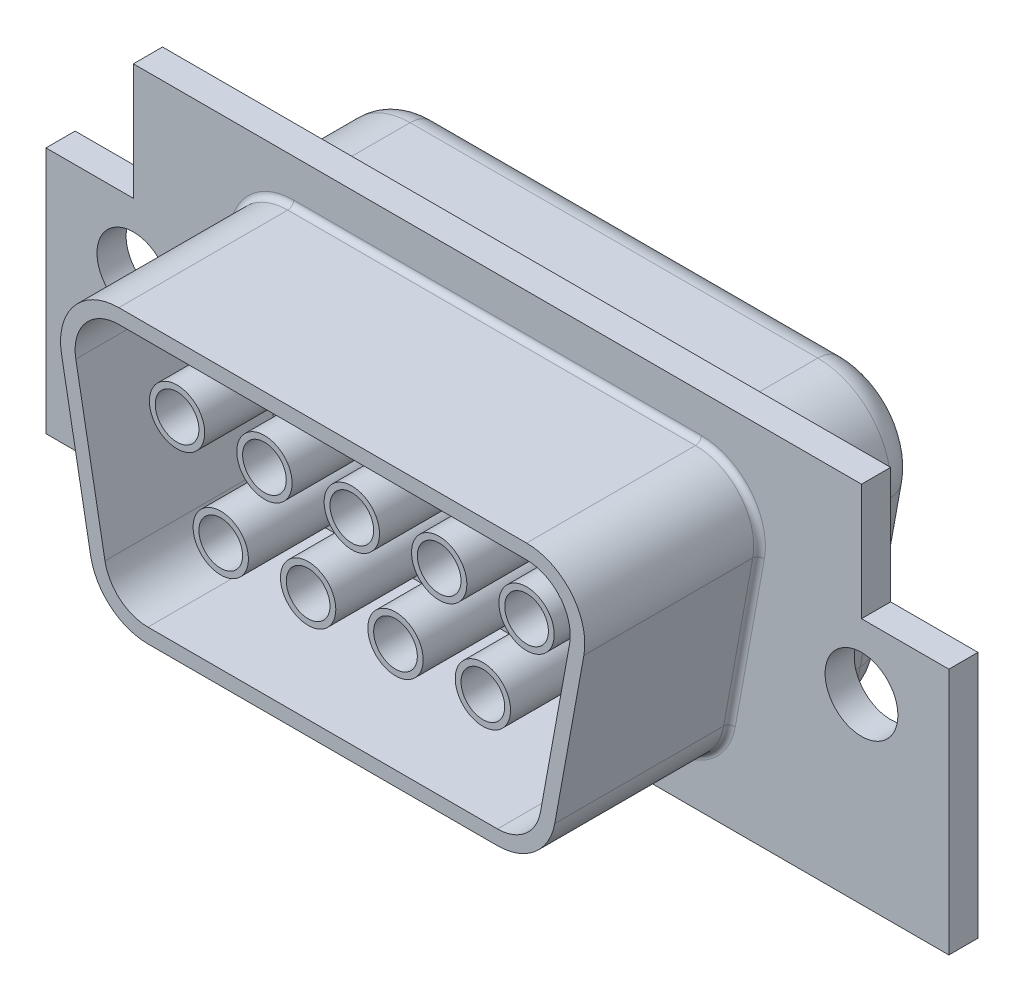
from build123d import *

# Parameters (mm, degrees)
SKETCH1_W                 = 31
SKETCH1_H                 = 12.5
EXTRUDE1_DEPTH            = 1
EXTRUDE2_DEPTH            = 6
FILLET1_R                 = 0.2
M3X0_5_TAPPED_HOLE1_D     = 2.5
M3X0_5_TAPPED_HOLE1_DEPTH = 17.5
M3X0_5_TAPPED_HOLE1_TIP   = 0.751075774
EXTRUDE3_DEPTH            = 4
FILLET2_R                 = 1
EXTRUDE4_DEPTH            = 0.5
SKETCH8_R                 = 0.95
SKETCH8_R_2               = 0.75
EXTRUDE_THIN2_DEPTH       = 5
SKETCH10_W                = 6.420651052
SKETCH10_H                = 6.175896966
SKETCH10_W_2              = 7.637064352
SKETCH10_H_2              = 8.744155905
CUT_EXTRUDE1_DEPTH        = 5


with BuildPart() as part:
    # Sketch1 → Extrude1 (new body)
    with BuildSketch(Plane.XY):
        Rectangle(SKETCH1_W, SKETCH1_H)
    extrude(amount=EXTRUDE1_DEPTH)

    # Sketch2 → Extrude2 (add)
    with BuildSketch(Plane.XY.offset(1)):
        with BuildLine():
            Line((-7, 4.75), (7, 4.75))
            ThreePointArc((7, 4.75), (8.53550346, 4.031494878), (8.96773982, 2.392229124))
            Line((8.96773982, 2.392229124), (7.96773982, -3.107770876))
            ThreePointArc((7.96773982, -3.107770876), (7.281494878, -4.28550346), (6, -4.75))
            Line((6, -4.75), (-6, -4.75))
            ThreePointArc((-6, -4.75), (-7.281494878, -4.28550346), (-7.96773982, -3.107770876))
            Line((-7.96773982, -3.107770876), (-8.96773982, 2.392229124))
            ThreePointArc((-8.96773982, 2.392229124), (-8.53550346, 4.031494878), (-7, 4.75))
        make_face()
        with BuildLine():
            Line((-6, -4.25), (6, -4.25))
            ThreePointArc((6, -4.25), (6.961121159, -3.901627595), (7.475804865, -3.018328157))
            Line((7.475804865, -3.018328157), (8.475804865, 2.481671843))
            ThreePointArc((8.475804865, 2.481671843), (8.151627595, 3.711121159), (7, 4.25))
            Line((7, 4.25), (-7, 4.25))
            ThreePointArc((-7, 4.25), (-8.151627595, 3.711121159), (-8.475804865, 2.481671843))
            Line((-8.475804865, 2.481671843), (-7.475804865, -3.018328157))
            ThreePointArc((-7.475804865, -3.018328157), (-6.961121159, -3.901627595), (-6, -4.25))
        make_face(mode=Mode.SUBTRACT)
    extrude(amount=EXTRUDE2_DEPTH)

    # Fillet1
    fillet1_edges = [part.edges().sort_by_distance(p)[0] for p in [
        (-7.281494878, -4.28550346, 1),
        (0, -4.75, 1),
        (7.281494878, -4.28550346, 1),
        (8.46773982, -0.357770876, 1),
        (8.53550346, 4.031494878, 1),
        (0, 4.75, 1),
        (-8.53550346, 4.031494878, 1),
        (-8.46773982, -0.357770876, 1),
    ]]
    fillet(fillet1_edges, radius=FILLET1_R)

    # M3x0.5 Tapped Hole1
    with Locations(Plane(origin=(-12.5, 0, 1), x_dir=(1, 0, 0), z_dir=(0, 0, 1))):
        with Locations((0, 0), (25, 0)):
            Hole(M3X0_5_TAPPED_HOLE1_D / 2, depth=M3X0_5_TAPPED_HOLE1_DEPTH)
            with Locations((0, 0, -(M3X0_5_TAPPED_HOLE1_DEPTH + M3X0_5_TAPPED_HOLE1_TIP / 2))):  # 118° drill point
                Cone(0, M3X0_5_TAPPED_HOLE1_D / 2, M3X0_5_TAPPED_HOLE1_TIP, mode=Mode.SUBTRACT)

    # Sketch6 → Extrude3 (add)
    with BuildSketch(Plane(origin=(0, 0, 0), x_dir=(-1, 0, 0), z_dir=(0, 0, -1))):
        with BuildLine():
            Line((8.459674775, -3.197213595), (9.459674775, 2.302786405))
            ThreePointArc((9.459674775, 2.302786405), (8.919379325, 4.351868598), (7, 5.25))
            Line((7, 5.25), (-7, 5.25))
            ThreePointArc((-7, 5.25), (-8.919379325, 4.351868598), (-9.459674775, 2.302786405))
            Line((-9.459674775, 2.302786405), (-8.459674775, -3.197213595))
            ThreePointArc((-8.459674775, -3.197213595), (-7.601868598, -4.669379325), (-6, -5.25))
            Line((-6, -5.25), (6, -5.25))
            ThreePointArc((6, -5.25), (7.601868598, -4.669379325), (8.459674775, -3.197213595))
        make_face()
    extrude(amount=EXTRUDE3_DEPTH)

    # Fillet2
    fillet2_edges = [part.edges().sort_by_distance(p)[0] for p in [
        (0, 5.25, -4),
        (8.919379325, 4.351868598, -4),
        (8.959674775, -0.447213595, -4),
        (7.601868598, -4.669379325, -4),
        (0, -5.25, -4),
        (-7.601868598, -4.669379325, -4),
        (-8.959674775, -0.447213595, -4),
        (-8.919379325, 4.351868598, -4),
    ]]
    fillet(fillet2_edges, radius=FILLET2_R)

    # Sketch7 → Extrude4 (add)
    with BuildSketch(Plane(origin=(0, 0, -4), x_dir=(-1, 0, 0), z_dir=(0, 0, -1))):
        with BuildLine():
            Line((6.98386991, -2.928885438), (7.98386991, 2.571114562))
            ThreePointArc((7.98386991, 2.571114562), (7.76775173, 3.390747439), (7, 3.75))
            Line((7, 3.75), (-7, 3.75))
            ThreePointArc((-7, 3.75), (-7.76775173, 3.390747439), (-7.98386991, 2.571114562))
            Line((-7.98386991, 2.571114562), (-6.98386991, -2.928885438))
            ThreePointArc((-6.98386991, -2.928885438), (-6.640747439, -3.51775173), (-6, -3.75))
            Line((-6, -3.75), (6, -3.75))
            ThreePointArc((6, -3.75), (6.640747439, -3.51775173), (6.98386991, -2.928885438))
        make_face()
    extrude(amount=EXTRUDE4_DEPTH)

    # Sketch8 → Extrude-Thin2 (add)
    with BuildSketch(Plane.XY.offset(1)):
        with Locations((-6, 1.5)):
            Circle(SKETCH8_R)
        with Locations((-6, 1.5)):
            Circle(SKETCH8_R_2, mode=Mode.SUBTRACT)
        with Locations((-4.5, -1.5)):
            Circle(SKETCH8_R)
        with Locations((-4.5, -1.5)):
            Circle(SKETCH8_R_2, mode=Mode.SUBTRACT)
        with Locations((-3, 1.5)):
            Circle(SKETCH8_R)
        with Locations((-3, 1.5)):
            Circle(SKETCH8_R_2, mode=Mode.SUBTRACT)
        with Locations((1.5, -1.5)):
            Circle(SKETCH8_R)
        with Locations((1.5, -1.5)):
            Circle(SKETCH8_R_2, mode=Mode.SUBTRACT)
        with Locations((0, 1.5)):
            Circle(SKETCH8_R)
        with Locations((0, 1.5)):
            Circle(SKETCH8_R_2, mode=Mode.SUBTRACT)
        with Locations((-1.5, -1.5)):
            Circle(SKETCH8_R)
        with Locations((-1.5, -1.5)):
            Circle(SKETCH8_R_2, mode=Mode.SUBTRACT)
        with Locations((3, 1.5)):
            Circle(SKETCH8_R)
        with Locations((3, 1.5)):
            Circle(SKETCH8_R_2, mode=Mode.SUBTRACT)
        with Locations((4.5, -1.5)):
            Circle(SKETCH8_R)
        with Locations((4.5, -1.5)):
            Circle(SKETCH8_R_2, mode=Mode.SUBTRACT)
        with Locations((6, 1.5)):
            Circle(SKETCH8_R)
        with Locations((6, 1.5)):
            Circle(SKETCH8_R_2, mode=Mode.SUBTRACT)
    extrude(amount=EXTRUDE_THIN2_DEPTH)

    # Sketch10 → Cut-Extrude1 (cut)
    with BuildSketch(Plane.XY.offset(1)):
        with Locations((-15.710325526, 5.337948483)):
            Rectangle(SKETCH10_W, SKETCH10_H)
        with Locations((16.318532176, 6.622077953)):
            Rectangle(SKETCH10_W_2, SKETCH10_H_2)
    extrude(amount=-CUT_EXTRUDE1_DEPTH, mode=Mode.SUBTRACT)


solid = part.part
